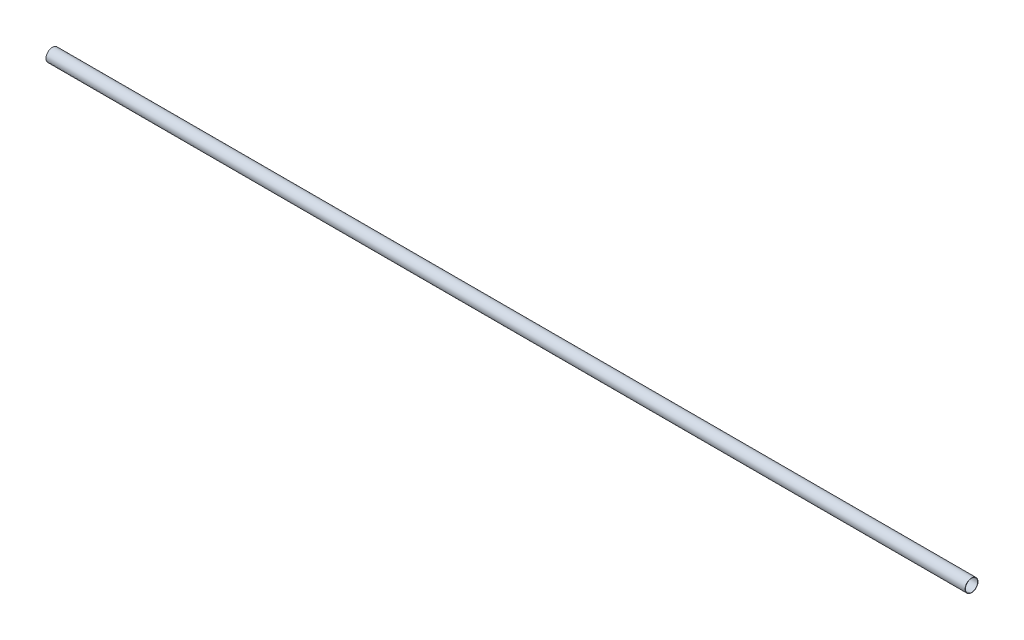
from build123d import *

# Parameters (mm, degrees)
SKETCH1_R           = 2.1
SKETCH1_R_2         = 2
EXTRUDE_THIN1_DEPTH = 300


with BuildPart() as part:
    # Sketch1 → Extrude-Thin1 (new body)
    with BuildSketch(Plane(origin=(0, 0, 0), x_dir=(0, 0, -1), z_dir=(1, 0, 0))):
        Circle(SKETCH1_R)
        Circle(SKETCH1_R_2, mode=Mode.SUBTRACT)
    extrude(amount=EXTRUDE_THIN1_DEPTH)


solid = part.part
